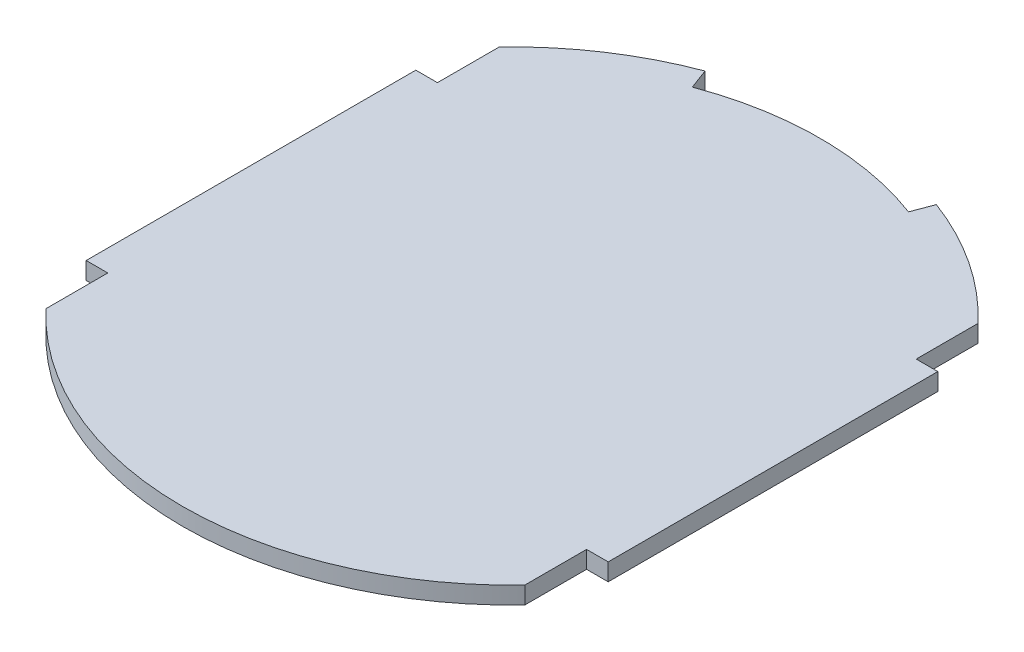
from build123d import *

# Parameters (mm, degrees)
BOSS_EXTRUDE1_DEPTH = 1.6
CUT_EXTRUDE1_DEPTH  = 10


with BuildPart() as part:
    # Sketch1 → Boss-Extrude1 (new body)
    with BuildSketch(Plane(origin=(0, 0, 0), x_dir=(1, 0, 0), z_dir=(0, 1, 0))):
        with BuildLine():
            Line((-24.15, 15.25), (-24.15, -15.25))
            Line((-24.15, -15.25), (-22.15, -15.25))
            Line((-22.15, -15.25), (-22.15, -20.967295963))
            ThreePointArc((-22.15, -20.967295963), (0, -30.5), (22.15, -20.967295963))
            Line((22.15, -20.967295963), (22.15, -15.25))
            Line((22.15, -15.25), (24.15, -15.25))
            Line((24.15, -15.25), (24.15, 15.25))
            Line((24.15, 15.25), (22.15, 15.25))
            Line((22.15, 15.25), (22.15, 20.967295963))
            ThreePointArc((22.15, 20.967295963), (0, 30.5), (-22.15, 20.967295963))
            Line((-22.15, 20.967295963), (-22.15, 15.25))
            Line((-22.15, 15.25), (-24.15, 15.25))
        make_face()
    extrude(amount=BOSS_EXTRUDE1_DEPTH)

    # Sketch2 → Cut-Extrude1 (cut)
    with BuildSketch(Plane(origin=(0, 1.6, 0), x_dir=(1, 0, 0), z_dir=(0, 1, 0))):
        with BuildLine():
            ThreePointArc((-10, 26.68801229), (0, 28.5), (10, 26.68801229))
            Line((10, 26.68801229), (10.701754386, 28.560855258))
            ThreePointArc((10.701754386, 28.560855258), (0, 30.5), (-10.701754386, 28.560855258))
            Line((-10.701754386, 28.560855258), (-10, 26.68801229))
        make_face()
    extrude(amount=-CUT_EXTRUDE1_DEPTH, mode=Mode.SUBTRACT)


solid = part.part
